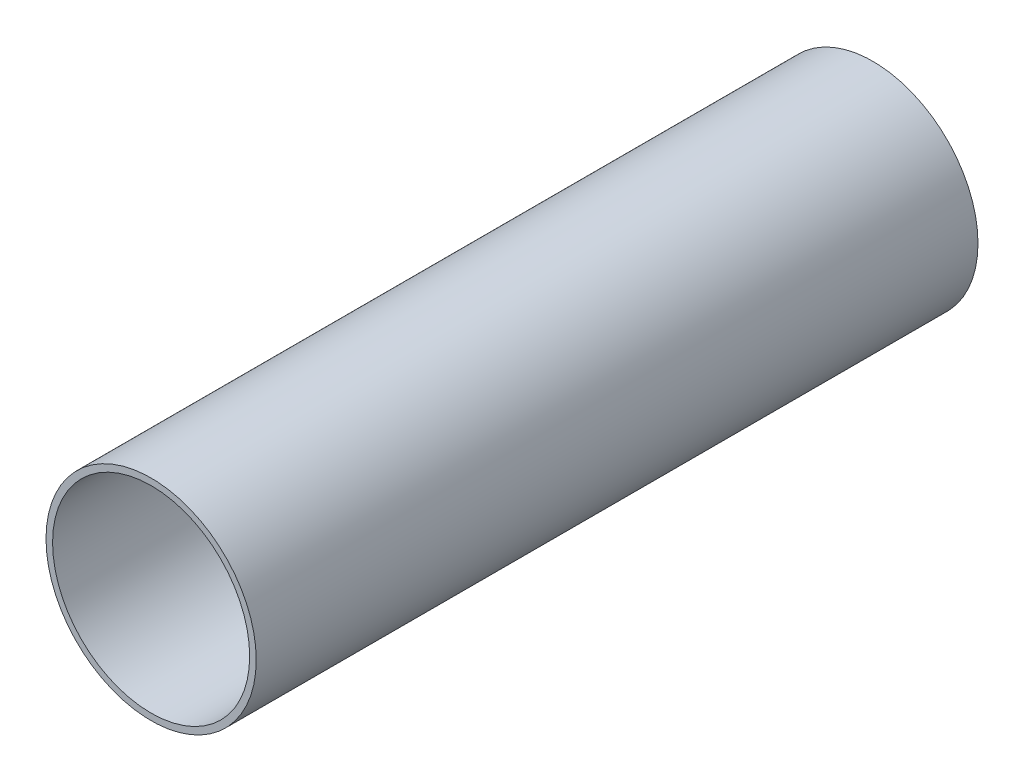
from build123d import *

# Parameters (mm, degrees)
PIPESKETCH_R    = 304.8
PIPESKETCH_R_2  = 285.75
EXTRUSION_DEPTH = 2092.8


with BuildPart() as part:
    # PipeSketch → Extrusion (new body)
    with BuildSketch(Plane.XY):
        Circle(PIPESKETCH_R)
        Circle(PIPESKETCH_R_2, mode=Mode.SUBTRACT)
    extrude(amount=EXTRUSION_DEPTH)


solid = part.part
